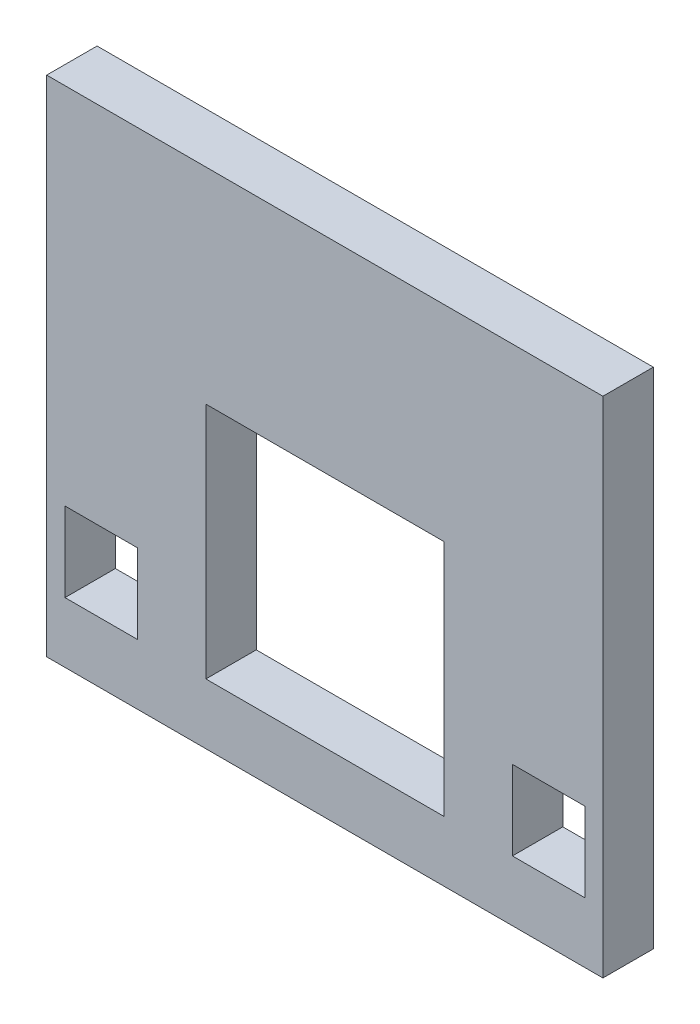
from build123d import *

# Parameters (mm, degrees)
SKETCH1_W           = 35.052
SKETCH1_H           = 31.75
BOSS_EXTRUDE1_DEPTH = 3.175
SKETCH2_W           = 15
SKETCH2_H           = 15
SKETCH2_W_2         = 4.56
SKETCH2_H_2         = 5
SKETCH2_W_3         = 4.559999976
CUT_EXTRUDE1_DEPTH  = 3.175


with BuildPart() as part:
    # Sketch1 → Boss-Extrude1 (new body)
    with BuildSketch(Plane.XY):
        with Locations((27.296391118, 15.000242991)):
            Rectangle(SKETCH1_W, SKETCH1_H)
    extrude(amount=BOSS_EXTRUDE1_DEPTH)

    # Sketch2 → Cut-Extrude1 (cut)
    with BuildSketch(Plane.XY.offset(3.175)):
        with Locations((27.301391118, 10.435242991)):
            Rectangle(SKETCH2_W, SKETCH2_H)
        with Locations((41.399391118, 5.435242991)):
            Rectangle(SKETCH2_W_2, SKETCH2_H_2)
        with Locations((13.20339113, 5.435242991)):
            Rectangle(SKETCH2_W_3, SKETCH2_H_2)
    extrude(amount=-CUT_EXTRUDE1_DEPTH, mode=Mode.SUBTRACT)


solid = part.part
